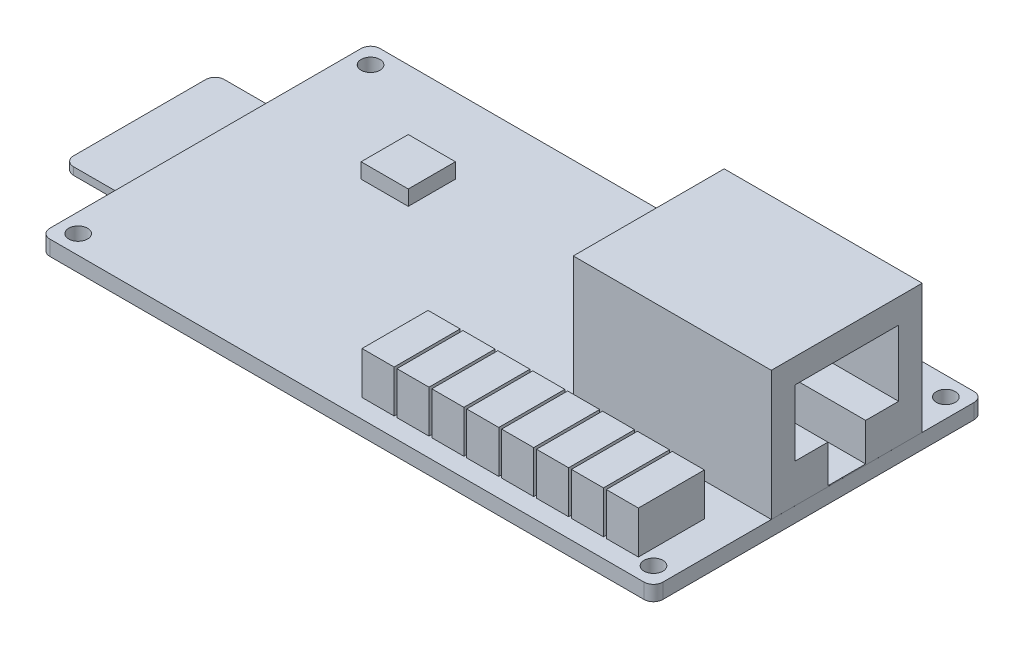
from build123d import *

# Parameters (mm, degrees)
SKIZZE1_W                       = 65
SKIZZE1_H                       = 35
SKIZZE1_R                       = 1
AUFSATZ_LINEAR_AUSTRAGEN1_DEPTH = 1.6
VERRUNDUNG1_R                   = 1
SKIZZE2_W                       = 18
SKIZZE2_H                       = 16
AUFSATZ_LINEAR_AUSTRAGEN2_DEPTH = 3
SKIZZE3_W                       = 15.998
SKIZZE3_H                       = 0.8
AUFSATZ_LINEAR_AUSTRAGEN3_DEPTH = 7
VERRUNDUNG2_R                   = 1
SKIZZE4_W                       = 21
SKIZZE4_H                       = 16
AUFSATZ_LINEAR_AUSTRAGEN4_DEPTH = 13.7
SCHNITT_LINEAR_AUSTRAGEN1_DEPTH = 12
SKIZZE6_W                       = 3.4
SKIZZE6_H                       = 7
AUFSATZ_LINEAR_AUSTRAGEN5_DEPTH = 4.5
SKIZZE7_W                       = 5
SKIZZE7_H                       = 5
AUFSATZ_LINEAR_AUSTRAGEN6_DEPTH = 1.8
SKIZZE8_W                       = 5
SKIZZE8_H                       = 5
AUFSATZ_LINEAR_AUSTRAGEN7_DEPTH = 1.6


with BuildPart() as part:
    # Skizze1 → Aufsatz-Linear austragen1 (new body)
    with BuildSketch(Plane(origin=(0, 0, 0), x_dir=(1, 0, 0), z_dir=(0, 1, 0))):
        Rectangle(SKIZZE1_W, SKIZZE1_H)
        with Locations((-30.5, -15.5)):
            Circle(SKIZZE1_R, mode=Mode.SUBTRACT)
        with Locations((30.5, -15.5)):
            Circle(SKIZZE1_R, mode=Mode.SUBTRACT)
        with Locations((30.5, 15.5)):
            Circle(SKIZZE1_R, mode=Mode.SUBTRACT)
        with Locations((-30.5, 15.5)):
            Circle(SKIZZE1_R, mode=Mode.SUBTRACT)
    extrude(amount=AUFSATZ_LINEAR_AUSTRAGEN1_DEPTH)

    # Verrundung1
    verrundung1_edges = [part.edges().sort_by_distance(p)[0] for p in [
        (32.5, 0.8, -17.5),
        (32.5, 0.8, 17.5),
        (-32.5, 0.8, 17.5),
        (-32.5, 0.8, -17.5),
    ]]
    fillet(verrundung1_edges, radius=VERRUNDUNG1_R)

    # Skizze2 → Aufsatz-Linear austragen2 (add)
    with BuildSketch(Plane.XZ):
        with Locations((-23.49, 0)):
            Rectangle(SKIZZE2_W, SKIZZE2_H)
    extrude(amount=AUFSATZ_LINEAR_AUSTRAGEN2_DEPTH)

    # Skizze3 → Aufsatz-Linear austragen3 (add)
    with BuildSketch(Plane.ZY.offset(32.49)):
        with Locations((0, -0.401)):
            Rectangle(SKIZZE3_W, SKIZZE3_H)
    extrude(amount=AUFSATZ_LINEAR_AUSTRAGEN3_DEPTH)

    # Verrundung2
    verrundung2_edges = [part.edges().sort_by_distance(p)[0] for p in [
        (-39.49, -0.401, -7.999),
        (-39.49, -0.401, 7.999),
    ]]
    fillet(verrundung2_edges, radius=VERRUNDUNG2_R)

    # Skizze4 → Aufsatz-Linear austragen4 (add)
    with BuildSketch(Plane(origin=(0, 1.6, 0), x_dir=(1, 0, 0), z_dir=(0, 1, 0))):
        with Locations((21.999, 3)):
            Rectangle(SKIZZE4_W, SKIZZE4_H)
    extrude(amount=AUFSATZ_LINEAR_AUSTRAGEN4_DEPTH)

    # Skizze5 → Schnitt-Linear austragen1 (cut)
    with BuildSketch(Plane(origin=(32.499, 0, 0), x_dir=(0, 0, -1), z_dir=(1, 0, 0))):
        Polygon((8.5, 12.7), (-2.5, 12.7), (-2.5, 5.7), (1, 5.7), (1, 1.7), (5, 1.7), (5, 5.7), (8.5, 5.7), align=None)
    extrude(amount=-SCHNITT_LINEAR_AUSTRAGEN1_DEPTH, mode=Mode.SUBTRACT)

    # Skizze6 → Aufsatz-Linear austragen5 (add)
    with BuildSketch(Plane(origin=(0, 1.6, 0), x_dir=(1, 0, 0), z_dir=(0, 1, 0))):
        with Locations((27.2, -12)):
            Rectangle(SKIZZE6_W, SKIZZE6_H)
        with Locations((23.5, -12)):
            Rectangle(SKIZZE6_W, SKIZZE6_H)
        with Locations((19.8, -12)):
            Rectangle(SKIZZE6_W, SKIZZE6_H)
        with Locations((16.1, -12)):
            Rectangle(SKIZZE6_W, SKIZZE6_H)
        with Locations((12.4, -12)):
            Rectangle(SKIZZE6_W, SKIZZE6_H)
        with Locations((8.7, -12)):
            Rectangle(SKIZZE6_W, SKIZZE6_H)
        with Locations((5, -12)):
            Rectangle(SKIZZE6_W, SKIZZE6_H)
        with Locations((1.3, -12)):
            Rectangle(SKIZZE6_W, SKIZZE6_H)
    extrude(amount=AUFSATZ_LINEAR_AUSTRAGEN5_DEPTH)

    # Skizze7 → Aufsatz-Linear austragen6 (add)
    with BuildSketch(Plane.XZ):
        with Locations((-0.5, 0)):
            Rectangle(SKIZZE7_W, SKIZZE7_H)
    extrude(amount=AUFSATZ_LINEAR_AUSTRAGEN6_DEPTH)

    # Skizze8 → Aufsatz-Linear austragen7 (add)
    with BuildSketch(Plane(origin=(0, 1.6, 0), x_dir=(1, 0, 0), z_dir=(0, 1, 0))):
        with Locations((-18, 7)):
            Rectangle(SKIZZE8_W, SKIZZE8_H)
    extrude(amount=AUFSATZ_LINEAR_AUSTRAGEN7_DEPTH)


solid = part.part
